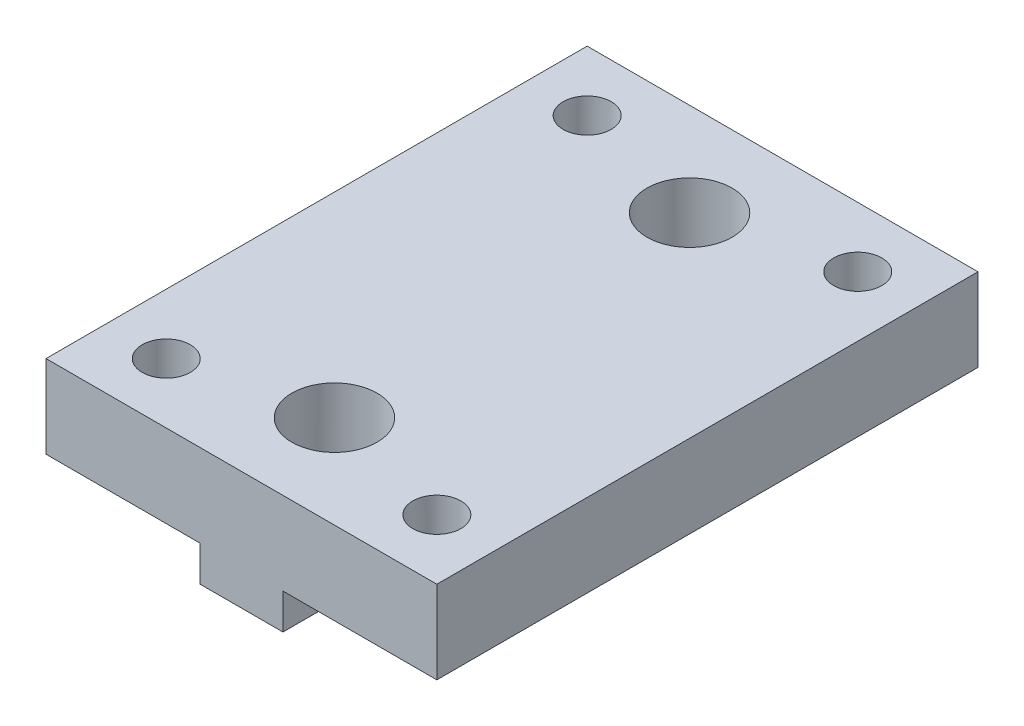
from build123d import *

# Parameters (mm, degrees)
SKETCH1_W           = 33.02
SKETCH1_H           = 45.72
SKETCH1_R           = 2.032
BOSS_EXTRUDE1_DEPTH = 10
SKETCH2_R           = 3.6
CUT_EXTRUDE1_DEPTH  = 10
SKETCH4_W           = 13
SKETCH4_H           = 45.72
CUT_EXTRUDE4_DEPTH  = 3


with BuildPart() as part:
    # Sketch1 → Boss-Extrude1 (new body)
    with BuildSketch(Plane(origin=(0, 0, 0), x_dir=(1, 0, 0), z_dir=(0, 1, 0))):
        Rectangle(SKETCH1_W, SKETCH1_H)
        with Locations((-11.43, 17.78)):
            Circle(SKETCH1_R, mode=Mode.SUBTRACT)
        with Locations((11.43, 17.78)):
            Circle(SKETCH1_R, mode=Mode.SUBTRACT)
        with Locations((-11.43, -17.78)):
            Circle(SKETCH1_R, mode=Mode.SUBTRACT)
        with Locations((11.43, -17.78)):
            Circle(SKETCH1_R, mode=Mode.SUBTRACT)
    extrude(amount=BOSS_EXTRUDE1_DEPTH)

    # Sketch2 → Cut-Extrude1 (cut)
    with BuildSketch(Plane(origin=(0, 10, 0), x_dir=(1, 0, 0), z_dir=(0, 1, 0))):
        with Locations((0, 15)):
            Circle(SKETCH2_R)
        with Locations((0, -15)):
            Circle(SKETCH2_R)
    extrude(amount=-CUT_EXTRUDE1_DEPTH, mode=Mode.SUBTRACT)

    # Sketch4 → Cut-Extrude4 (cut)
    with BuildSketch(Plane.XZ):
        with Locations((10.01, 0)):
            Rectangle(SKETCH4_W, SKETCH4_H)
        with Locations((-10.01, 0)):
            Rectangle(SKETCH4_W, SKETCH4_H)
    extrude(amount=-CUT_EXTRUDE4_DEPTH, mode=Mode.SUBTRACT)


solid = part.part
